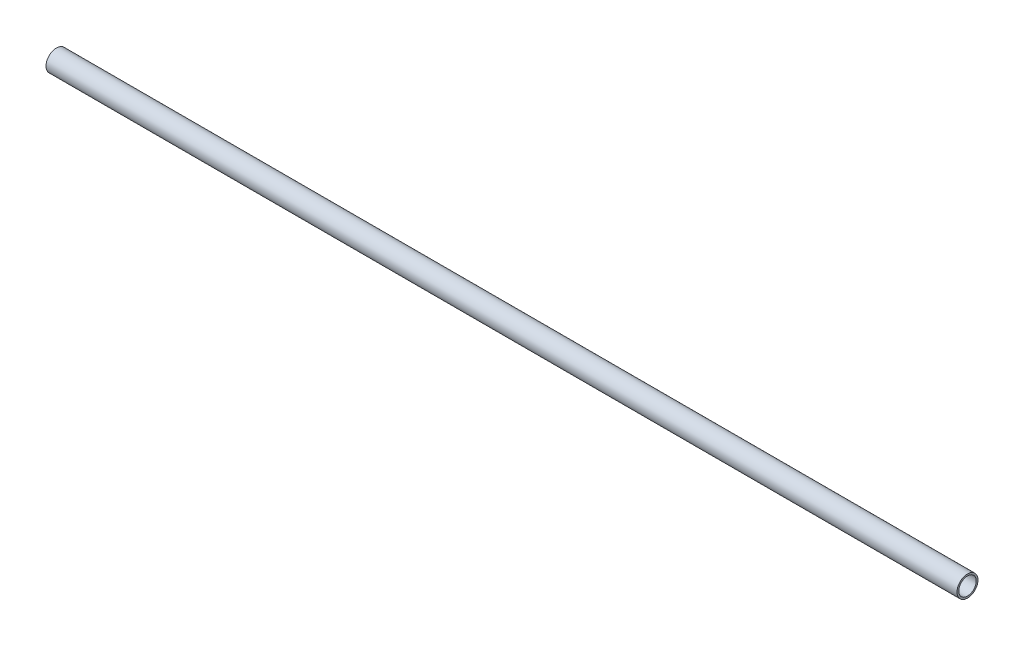
from build123d import *

# Parameters (mm, degrees)
SKETCH1_R                = 21.082
SKETCH1_R_2              = 17.526
BOSS_EXTRUDE1_DEPTH      = 914.4
BOSS_EXTRUDE1_DEPTH_BACK = 914.4
SKETCH2_R                = 3.175
CUT_EXTRUDE1_DEPTH       = 22.082


with BuildPart() as part:
    # Sketch1 → Boss-Extrude1 (new body, two sides)
    with BuildSketch(Plane(origin=(0, 0, 0), x_dir=(0, 0, -1), z_dir=(1, 0, 0))) as boss_extrude1_sk:
        Circle(SKETCH1_R)
        Circle(SKETCH1_R_2, mode=Mode.SUBTRACT)
    extrude(amount=BOSS_EXTRUDE1_DEPTH)
    extrude(boss_extrude1_sk.sketch, amount=-BOSS_EXTRUDE1_DEPTH_BACK)

    # Sketch2 → Cut-Extrude1 (cut, through all)
    with BuildSketch(Plane.XY):
        with Locations((-831.85, 0)):
            Circle(SKETCH2_R)
        with Locations((-882.65, 0)):
            Circle(SKETCH2_R)
    cut_extrude1 = extrude(amount=-CUT_EXTRUDE1_DEPTH, mode=Mode.SUBTRACT)

    # Mirror1: Cut-Extrude1 across plane
    add(cut_extrude1.mirror(Plane(origin=(0, 0, 0), x_dir=(0, 0, 1), z_dir=(1, 0, 0))), mode=Mode.SUBTRACT)


solid = part.part
